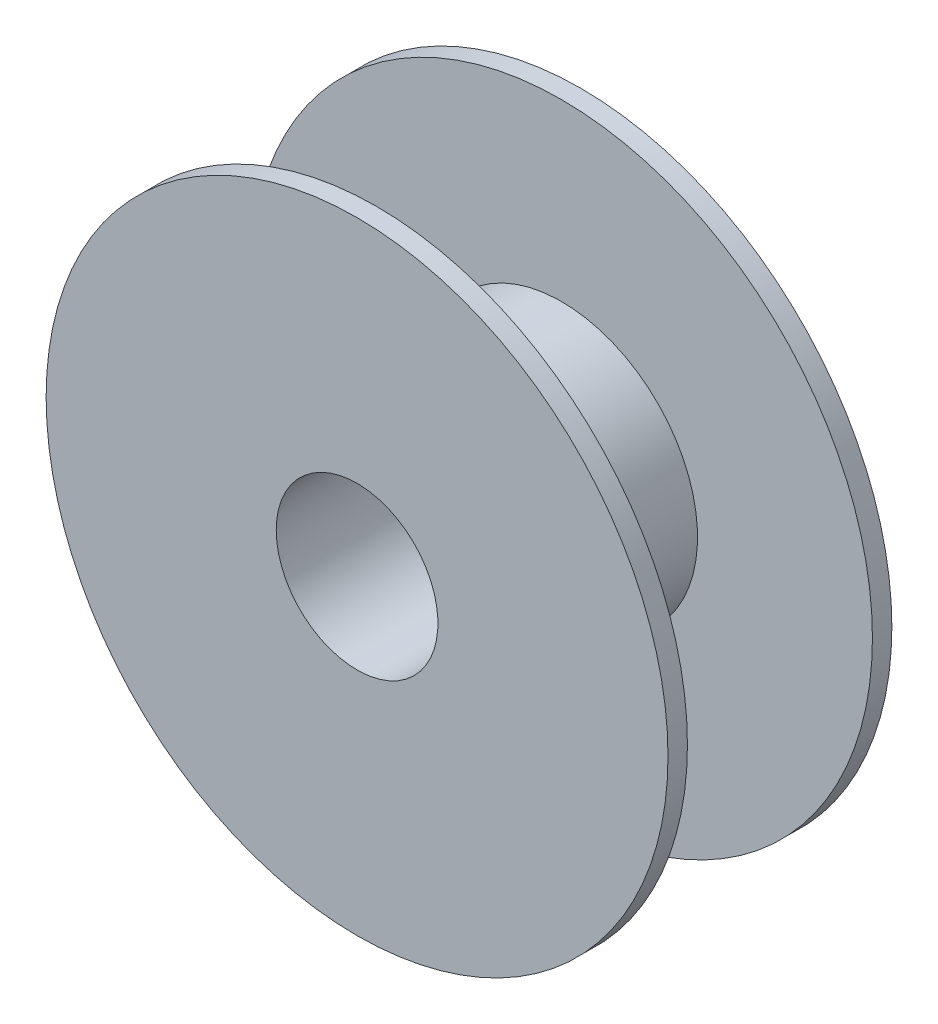
from build123d import *

# Parameters (mm, degrees)
SKETCH1_R           = 101.6
BOSS_EXTRUDE1_DEPTH = 73.152
SKETCH3_W           = 60.452
SKETCH3_H           = 57.15
SKETCH4_R           = 26.416
CUT_EXTRUDE1_DEPTH  = 73.152


with BuildPart() as part:
    # Sketch1 → Boss-Extrude1 (new body)
    with BuildSketch(Plane.XY):
        Circle(SKETCH1_R)
    extrude(amount=BOSS_EXTRUDE1_DEPTH)

    # Sketch3 → Cut-Revolve2 (revolve, cut)
    with BuildSketch(Plane(origin=(0, 0, 0), x_dir=(0, 0, -1), z_dir=(1, 0, 0))):
        with Locations((-36.576, 73.025)):
            Rectangle(SKETCH3_W, SKETCH3_H)
    revolve(axis=Axis((0, 0, 0), (0, 0, 1)), mode=Mode.SUBTRACT)

    # Sketch4 → Cut-Extrude1 (cut)
    with BuildSketch(Plane(origin=(0, 0, 0), x_dir=(-1, 0, 0), z_dir=(0, 0, -1))):
        Circle(SKETCH4_R)
    extrude(amount=-CUT_EXTRUDE1_DEPTH, mode=Mode.SUBTRACT)


solid = part.part
